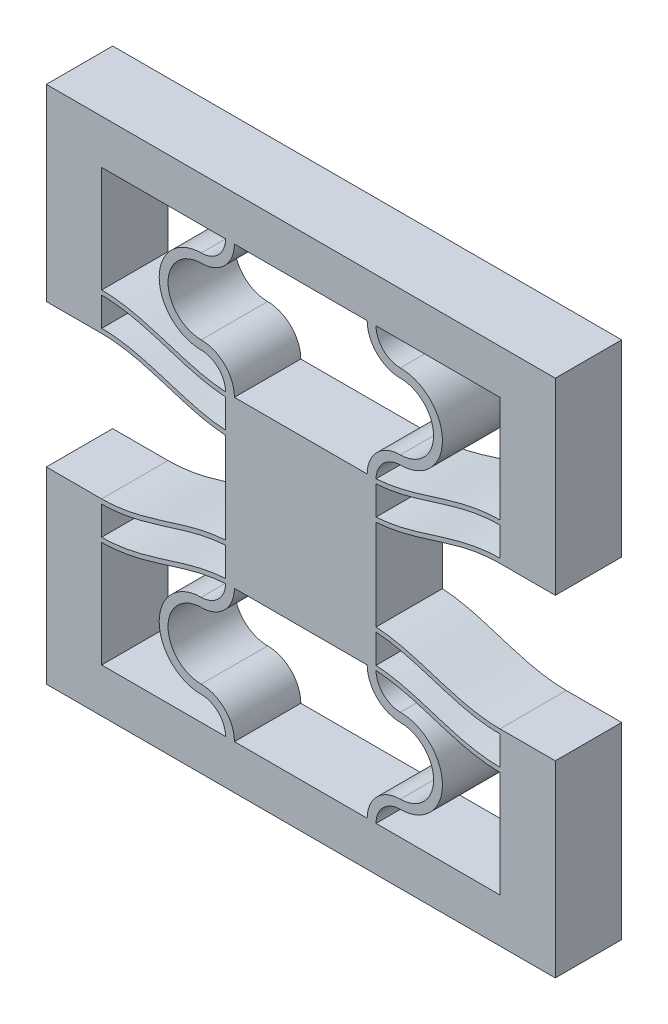
from build123d import *

# Parameters (mm, degrees)
BOSS_EXTRUDE1_DEPTH = 2
SKETCH4_W           = 1.600312859
SKETCH4_H           = 2
BOSS_EXTRUDE2_DEPTH = 1.5
SKETCH7_W           = 2
SKETCH7_H           = 4
SKETCH7_H_2         = 14.947530341
BOSS_EXTRUDE3_DEPTH = 6
MOVE_FACE2_BY       = 4


with BuildPart() as part:
    # Sketch1 → Boss-Extrude1 (new body)
    with BuildSketch(Plane.XY):
        with BuildLine():
            add(Edge.make_bspline(
                [(12.800155935, 15.373765172), (12.829443053, 15.371851728), (13.087720515, 15.354165904), (13.574058367, 15.307412755), (14.442532918, 15.180190583), (15.494982528, 14.945600854), (16.422391817, 14.687198607), (17.233400126, 14.440241963), (17.781066315, 14.268924734), (18.218924791, 14.131071213), (18.6570939, 13.994024873), (19.095929435, 13.859458026), (19.612496477, 13.706397169), (20.207834189, 13.540304481), (20.919328674, 13.362082485), (21.637160393, 13.214701271), (22.283649653, 13.113489773), (22.796037337, 13.056535024), (23.141074959, 13.028755819), (23.424763559, 13.012615939), (23.650809178, 13.003971123), (23.854556177, 13.000721307), (23.952038323, 12.999999125), (24.000000006, 12.999999125)],
                knots=[0.527226126, 0.527226126, 0.527226126, 0.527226126, 0.527226126, 0.531217871, 0.562435738, 0.59365362, 0.646518629, 0.677736523, 0.69334547, 0.708954416, 0.724563367, 0.740172317, 0.755781267, 0.771390217, 0.797822721, 0.824255224, 0.855473084, 0.871082016, 0.886690949, 0.89449542, 0.902299891, 0.910104362, 0.917908833, 0.917908833, 0.917908833, 0.917908833, 0.917908833], degree=4))
            Line((12.800155935, 15.373765172), (12.800155935, 17.973765171))
            Line((12.800155935, 17.973765171), (11.199843076, 17.973765171))
            Line((11.199843076, 17.973765171), (11.199843076, 15.373765171))
            add(Edge.make_bspline(
                [(6e-09, 12.999999125), (0.047961688, 12.999999125), (0.145439169, 13.000721314), (0.349142853, 13.003971192), (0.575417274, 13.012615694), (0.801781982, 13.025528326), (1.031941061, 13.04264506), (1.260329999, 13.063882065), (1.488433729, 13.089137172), (1.773068694, 13.125578683), (2.113552779, 13.176836879), (2.587502675, 13.260854092), (3.192230615, 13.389986055), (3.792042415, 13.540308006), (4.387572632, 13.706392302), (4.904034238, 13.859462583), (5.342923088, 13.994019459), (6.109682116, 14.233863386), (7.136551186, 14.559271576), (8.280773867, 14.895597816), (9.55746877, 15.180199223), (10.425941111, 15.307410183), (10.912278805, 15.354165018), (11.170556163, 15.371851651), (11.199843076, 15.373765171)],
                knots=[0.082091167, 0.082091167, 0.082091167, 0.082091167, 0.082091167, 0.089895638, 0.097700109, 0.10550458, 0.113309051, 0.121113517, 0.128917984, 0.13672245, 0.144526916, 0.160135846, 0.175744776, 0.202177279, 0.228609783, 0.244218733, 0.259827683, 0.275436633, 0.291045584, 0.353481371, 0.40634638, 0.437564262, 0.468782129, 0.472773844, 0.472773844, 0.472773844, 0.472773844, 0.472773844], degree=4))
            Line((5e-09, 12.999999125), (-5.000000009, 12.999999125))
            Line((-5.000000009, 12.999999125), (-5.000000009, -4))
            Line((-5.000000009, -4), (29.00000002, -4))
            Line((29.00000002, -4), (29.00000002, 12.999999125))
            Line((29.00000002, 12.999999125), (24.000000006, 12.999999125))
        make_face()
        with BuildLine():
            Line((11.199843076, 14.973765171), (11.199843076, 12.37376517))
            add(Edge.make_bspline(
                [(1.8e-08, 9.999999125), (0.0479617, 9.999999125), (0.145439181, 10.000721314), (0.349142865, 10.003971192), (0.575417286, 10.012615694), (0.801781994, 10.025528326), (1.031941073, 10.04264506), (1.260330011, 10.063882065), (1.488433741, 10.089137172), (1.773068706, 10.125578683), (2.11355279, 10.176836879), (2.587502686, 10.260854092), (3.192230627, 10.389986055), (3.792042427, 10.540308006), (4.387572643, 10.706392302), (4.904034249, 10.859462583), (5.3429231, 10.994019459), (6.109682128, 11.233863386), (7.136551198, 11.559271576), (8.280773879, 11.895597816), (9.557468782, 12.180199223), (10.42594112, 12.307410183), (10.912278811, 12.354165018), (11.170556166, 12.371851651), (11.199843076, 12.37376517)],
                knots=[0.082091167, 0.082091167, 0.082091167, 0.082091167, 0.082091167, 0.089895638, 0.097700109, 0.10550458, 0.113309051, 0.121113517, 0.128917984, 0.13672245, 0.144526916, 0.160135846, 0.175744776, 0.202177279, 0.228609783, 0.244218733, 0.259827683, 0.275436633, 0.291045584, 0.353481371, 0.40634638, 0.437564262, 0.468782129, 0.472773844, 0.472773844, 0.472773844, 0.472773844, 0.472773844], degree=4))
            Line((1.7e-08, 9.999999125), (4e-09, 12.599999125))
            add(Edge.make_bspline(
                [(5e-09, 12.599999125), (0.047961687, 12.599999125), (0.145439168, 12.600721314), (0.349142852, 12.603971192), (0.575417273, 12.612615694), (0.801781981, 12.625528326), (1.03194106, 12.64264506), (1.260329998, 12.663882065), (1.488433728, 12.689137172), (1.773068693, 12.725578683), (2.113552777, 12.776836879), (2.587502673, 12.860854092), (3.192230614, 12.989986055), (3.792042414, 13.140308006), (4.38757263, 13.306392302), (4.904034236, 13.459462583), (5.342923087, 13.594019459), (6.109682115, 13.833863386), (7.136551185, 14.159271576), (8.280773866, 14.495597816), (9.557468769, 14.780199223), (10.42594111, 14.907410183), (10.912278805, 14.954165018), (11.170556162, 14.971851651), (11.199843076, 14.973765171)],
                knots=[0.082091167, 0.082091167, 0.082091167, 0.082091167, 0.082091167, 0.089895638, 0.097700109, 0.10550458, 0.113309051, 0.121113517, 0.128917984, 0.13672245, 0.144526916, 0.160135846, 0.175744776, 0.202177279, 0.228609783, 0.244218733, 0.259827683, 0.275436633, 0.291045584, 0.353481371, 0.40634638, 0.437564262, 0.468782129, 0.472773844, 0.472773844, 0.472773844, 0.472773844, 0.472773844], degree=4))
        make_face(mode=Mode.SUBTRACT)
        with BuildLine():
            Line((12.800155935, 12.373765172), (12.800155935, 14.973765171))
            add(Edge.make_bspline(
                [(12.800155935, 14.973765171), (12.829443053, 14.971851728), (13.087720514, 14.954165904), (13.574058366, 14.907412755), (14.442532917, 14.780190583), (15.494982527, 14.545600854), (16.422391815, 14.287198607), (17.233400124, 14.040241963), (17.781066314, 13.868924734), (18.218924789, 13.731071213), (18.657093899, 13.594024873), (19.095929434, 13.459458026), (19.612496476, 13.306397169), (20.207834188, 13.140304481), (20.919328673, 12.962082485), (21.637160392, 12.814701271), (22.283649652, 12.713489773), (22.796037336, 12.656535024), (23.141074957, 12.628755819), (23.424763557, 12.612615939), (23.650809176, 12.603971123), (23.854556176, 12.600721307), (23.952038322, 12.599999125), (24.000000005, 12.599999125)],
                knots=[0.527226126, 0.527226126, 0.527226126, 0.527226126, 0.527226126, 0.531217871, 0.562435738, 0.59365362, 0.646518629, 0.677736523, 0.69334547, 0.708954416, 0.724563367, 0.740172317, 0.755781267, 0.771390217, 0.797822721, 0.824255224, 0.855473084, 0.871082016, 0.886690949, 0.89449542, 0.902299891, 0.910104362, 0.917908833, 0.917908833, 0.917908833, 0.917908833, 0.917908833], degree=4))
            Line((24, 12.599999125), (24.000000015, 9.999999125))
            add(Edge.make_bspline(
                [(12.800155935, 12.373765172), (12.829443056, 12.371851729), (13.087720521, 12.354165905), (13.574058376, 12.307412756), (14.44253293, 12.180190583), (15.494982539, 11.945600854), (16.422391828, 11.687198607), (17.233400137, 11.440241963), (17.781066327, 11.268924734), (18.218924802, 11.131071213), (18.657093912, 10.994024873), (19.095929447, 10.859458026), (19.612496489, 10.706397169), (20.207834201, 10.540304481), (20.919328686, 10.362082485), (21.637160405, 10.214701271), (22.283649665, 10.113489773), (22.796037349, 10.056535024), (23.14107497, 10.028755819), (23.42476357, 10.012615939), (23.650809189, 10.003971123), (23.854556189, 10.000721307), (23.952038335, 9.999999125), (24.000000018, 9.999999125)],
                knots=[0.527226126, 0.527226126, 0.527226126, 0.527226126, 0.527226126, 0.531217871, 0.562435738, 0.59365362, 0.646518629, 0.677736523, 0.69334547, 0.708954416, 0.724563367, 0.740172317, 0.755781267, 0.771390217, 0.797822721, 0.824255224, 0.855473084, 0.871082016, 0.886690949, 0.89449542, 0.902299891, 0.910104362, 0.917908833, 0.917908833, 0.917908833, 0.917908833, 0.917908833], degree=4))
        make_face(mode=Mode.SUBTRACT)
        with BuildLine():
            Line((0, 0), (0, 9.599999125))
            add(Edge.make_bspline(
                [(1e-09, 9.599999125), (0.047961683, 9.599999125), (0.145439165, 9.600721314), (0.349142848, 9.603971192), (0.575417269, 9.612615694), (0.801781977, 9.625528326), (1.031941056, 9.64264506), (1.260329995, 9.663882065), (1.488433724, 9.689137173), (1.773068689, 9.725578683), (2.113552774, 9.776836879), (2.58750267, 9.860854093), (3.19223061, 9.989986055), (3.79204241, 10.140308006), (4.387572627, 10.306392303), (4.904034233, 10.459462583), (5.342923083, 10.59401946), (6.109682111, 10.833863387), (7.136551181, 11.159271576), (8.280773862, 11.495597816), (9.557468765, 11.780199223), (10.425941108, 11.907410184), (10.912278803, 11.954165019), (11.170556161, 11.971851652), (11.199843076, 11.973765172)],
                knots=[0.082091167, 0.082091167, 0.082091167, 0.082091167, 0.082091167, 0.089895638, 0.097700109, 0.10550458, 0.113309051, 0.121113517, 0.128917984, 0.13672245, 0.144526916, 0.160135846, 0.175744776, 0.202177279, 0.228609783, 0.244218733, 0.259827683, 0.275436633, 0.291045584, 0.353481371, 0.40634638, 0.437564262, 0.468782129, 0.472773844, 0.472773844, 0.472773844, 0.472773844, 0.472773844], degree=4))
            ThreePointArc((11.199843076, 11.973765172), (10.546331193, 10.435117157), (8.999999505, 9.8))
            ThreePointArc((8.999999505, 9.8), (5.199999505, 6), (8.999999505, 2.2))
            ThreePointArc((8.999999505, 2.2), (10.555634424, 1.555634919), (11.199999505, 0))
            Line((11.199999505, 0), (0, 0))
        make_face(mode=Mode.SUBTRACT)
        with BuildLine():
            ThreePointArc((8.999999505, 9), (11.121319849, 9.878679656), (11.999999505, 12))
            ThreePointArc((11.999999505, 12), (12.878679162, 9.878679656), (14.999999505, 9))
            ThreePointArc((14.999999505, 9), (17.999999505, 6), (14.999999505, 3))
            ThreePointArc((14.999999505, 3), (12.878679162, 2.121320344), (11.999999505, 0))
            ThreePointArc((11.999999505, 0), (11.121319849, 2.121320344), (8.999999505, 3))
            ThreePointArc((8.999999505, 3), (5.999999505, 6), (8.999999505, 9))
        make_face(mode=Mode.SUBTRACT)
        with BuildLine():
            ThreePointArc((14.999999505, 9.8), (13.453667817, 10.435117157), (12.800155935, 11.973765172))
            add(Edge.make_bspline(
                [(12.800155935, 11.973765172), (12.829443052, 11.971851729), (13.087720512, 11.954165905), (13.574058363, 11.907412756), (14.442532913, 11.780190584), (15.494982523, 11.545600855), (16.422391812, 11.287198608), (17.23340012, 11.040241964), (17.78106631, 10.868924735), (18.218924786, 10.731071215), (18.657093895, 10.594024874), (19.09592943, 10.459458028), (19.612496472, 10.306397171), (20.207834184, 10.140304482), (20.919328669, 9.962082487), (21.637160388, 9.814701273), (22.283649648, 9.713489774), (22.796037332, 9.656535025), (23.141074954, 9.62875582), (23.424763554, 9.61261594), (23.650809173, 9.603971125), (23.854556172, 9.600721309), (23.952038318, 9.599999126), (24.000000001, 9.599999126)],
                knots=[0.527226126, 0.527226126, 0.527226126, 0.527226126, 0.527226126, 0.531217871, 0.562435738, 0.59365362, 0.646518629, 0.677736523, 0.69334547, 0.708954416, 0.724563367, 0.740172317, 0.755781267, 0.771390217, 0.797822721, 0.824255224, 0.855473084, 0.871082016, 0.886690949, 0.89449542, 0.902299891, 0.910104362, 0.917908833, 0.917908833, 0.917908833, 0.917908833, 0.917908833], degree=4))
            Line((24, 9.599999126), (24.000000015, 0))
            Line((24.000000015, 0), (12.799999505, 0))
            ThreePointArc((12.799999505, 0), (13.444364587, 1.555634919), (14.999999505, 2.2))
            ThreePointArc((14.999999505, 2.2), (18.799999505, 6), (14.999999505, 9.8))
        make_face(mode=Mode.SUBTRACT)
    extrude(amount=BOSS_EXTRUDE1_DEPTH)

    # Sketch4 → Boss-Extrude2 (add)
    with BuildSketch(Plane(origin=(0, 17.973765171, 0), x_dir=(1, 0, 0), z_dir=(0, 1, 0))):
        with Locations((11.999999505, -1)):
            Rectangle(SKETCH4_W, SKETCH4_H)
    extrude(amount=BOSS_EXTRUDE2_DEPTH)

    # Mirror3: part across plane


with BuildPart() as part_1:
    add(part.part)
    add(part.part.mirror(Plane.ZX.offset(19.473765171)))

    # Split2
    split(bisect_by=Plane(origin=(11.999999505, 0, 0), x_dir=(0, -1, 0), z_dir=(-1, 0, 0)), keep=Keep.BOTTOM)

    # Sketch7 → Boss-Extrude3 (add)
    with BuildSketch(Plane.ZY.offset(-11.999999505)):
        with Locations((1, 40.947530341)):
            Rectangle(SKETCH7_W, SKETCH7_H)
        with Locations((1, 19.473765171)):
            Rectangle(SKETCH7_W, SKETCH7_H_2)
        with Locations((1, -2)):
            Rectangle(SKETCH7_W, SKETCH7_H)
    extrude(amount=BOSS_EXTRUDE3_DEPTH)

    # Mirror2: part across plane


with BuildPart() as part_2:
    add(part_1.part)
    add(part_1.part.mirror(Plane.ZY.offset(-5.999999505)))

    # Move Face2: a face moved outward by 4.0
    extrude(part_2.faces().sort_by_distance((5.999999505, 19.473765171, 0))[0], amount=MOVE_FACE2_BY, dir=(0, 0, -1))


solid = part_2.part
